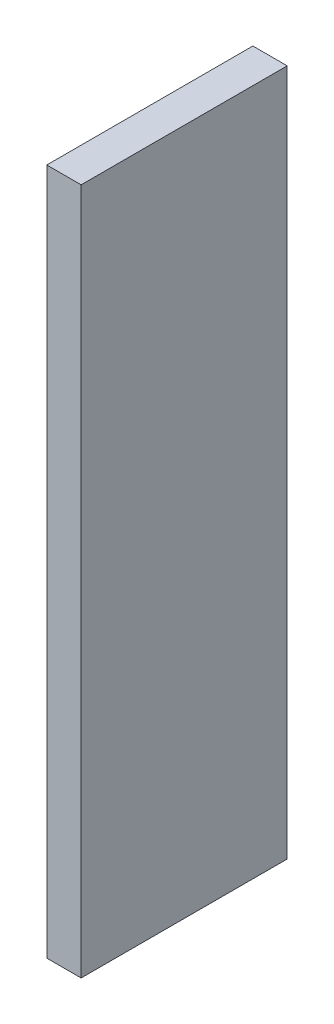
from build123d import *

# Parameters (mm, degrees)
ESQUISSE1_W        = 50
ESQUISSE1_H        = 1000
BOSS_EXTRU_1_DEPTH = 300


with BuildPart() as part:
    # Esquisse1 → Boss.-Extru.1 (new body)
    with BuildSketch(Plane.XY):
        with Locations((-8.39751142, 453.225914994)):
            Rectangle(ESQUISSE1_W, ESQUISSE1_H)
    extrude(amount=BOSS_EXTRU_1_DEPTH)


solid = part.part
